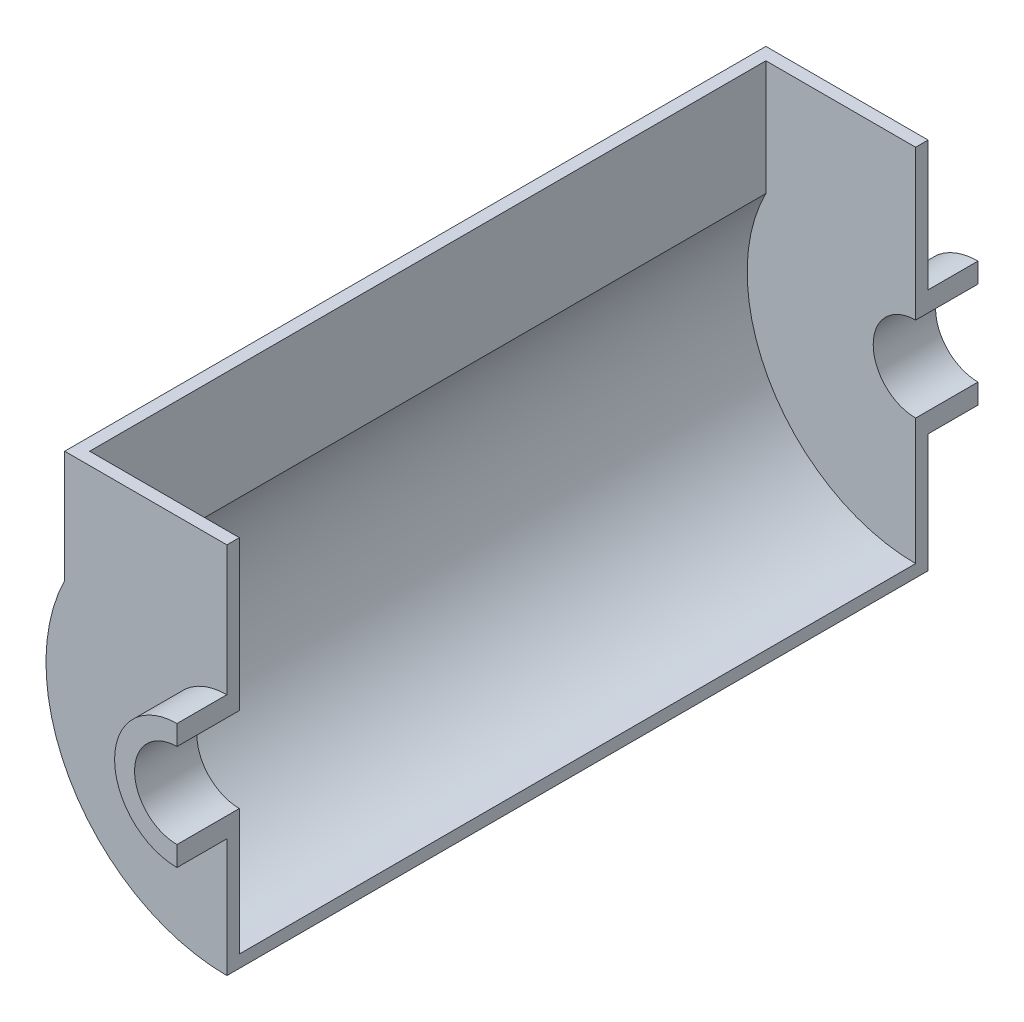
from build123d import *

# Parameters (mm, degrees)
BOSS_EXTRUDE1_DEPTH      = 20
BOSS_EXTRUDE1_DEPTH_BACK = 5
BOSS_EXTRUDE2_DEPTH      = 5
BOSS_EXTRUDE3_DEPTH      = 271


with BuildPart() as part:
    # Sketch1 → Boss-Extrude1 (new body, two sides)
    with BuildSketch(Plane.XY) as boss_extrude1_sk:
        with BuildLine():
            Line((0, 25), (0, 17))
            ThreePointArc((0, 17), (-17, 0), (0, -17))
            Line((0, -17), (0, -25))
            ThreePointArc((0, -25), (-25, 0), (0, 25))
        make_face()
    extrude(amount=BOSS_EXTRUDE1_DEPTH)
    extrude(boss_extrude1_sk.sketch, amount=-BOSS_EXTRUDE1_DEPTH_BACK)

    # Sketch2 → Boss-Extrude2 (add)
    with BuildSketch(Plane.XY):
        with BuildLine():
            Line((0, 25), (0, 77))
            Line((0, 77), (-65, 77))
            Line((-65, 77), (-65, 32.113081447))
            ThreePointArc((-65, 32.113081447), (-61.581037686, -38.262590053), (0, -72.5))
            Line((0, -72.5), (0, -25))
            ThreePointArc((0, -25), (-25, 0), (0, 25))
        make_face()
    extrude(amount=-BOSS_EXTRUDE2_DEPTH)


with BuildPart() as body_2:
    # Mirror2: mirrored copy
    add(part.part.mirror(Plane.XY.offset(-140.5)))


with BuildPart() as part_1:
    add(part.part)

    add(body_2.part)  # Boss-Extrude3 merges body 2
    # Sketch3 → Boss-Extrude3 (add)
    with BuildSketch(Plane(origin=(0, 0, -5), x_dir=(-1, 0, 0), z_dir=(0, 0, -1))):
        with BuildLine():
            Line((60, 77), (60, 30.923292192))
            ThreePointArc((60, 30.923292192), (57.634938288, -35.134938288), (0, -67.5))
            Line((0, -67.5), (0, -72.5))
            ThreePointArc((0, -72.5), (61.581037686, -38.262590053), (65, 32.113081447))
            Line((65, 32.113081447), (65, 77))
            Line((65, 77), (60, 77))
        make_face()
    extrude(amount=BOSS_EXTRUDE3_DEPTH)


solid = part_1.part
